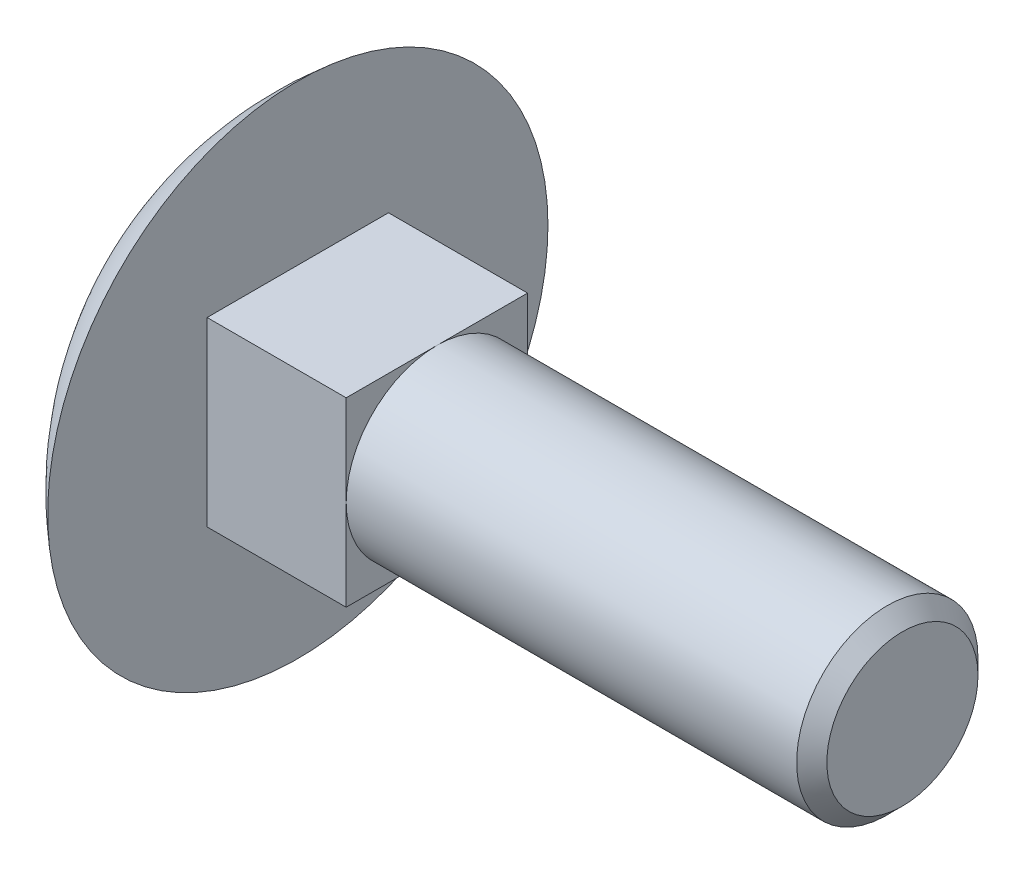
from build123d import *

# Parameters (mm, degrees)
SKIZZE2_W               = 6
SKIZZE2_H               = 6
LINEAR_AUSTRAGEN1_DEPTH = 4.6
SKIZZE3_R               = 3
LINEAR_AUSTRAGEN2_DEPTH = 15.4
FASE1_SIZE              = 0.5


with BuildPart() as part:
    # Skizze1 → Rotation1 (revolve)
    with BuildSketch(Plane(origin=(0, 0, 0), x_dir=(1, 0, 0), z_dir=(0, 1, 0))):
        with BuildLine():
            Line((0, 0), (0, 8.275))
            ThreePointArc((0, 8.275), (-2.861847997, 4.569738094), (-3.88, 0))
            Line((-3.88, 0), (0, 0))
        make_face()
    revolve(axis=Axis((0, 0, 0), (-1, 0, 0)))

    # Skizze2 → Linear austragen1 (add)
    with BuildSketch(Plane(origin=(0, 0, 0), x_dir=(0, 0, -1), z_dir=(1, 0, 0))):
        Rectangle(SKIZZE2_W, SKIZZE2_H)
    extrude(amount=LINEAR_AUSTRAGEN1_DEPTH)

    # Skizze3 → Linear austragen2 (add)
    with BuildSketch(Plane(origin=(4.6, 0, 0), x_dir=(0, 0, -1), z_dir=(1, 0, 0))):
        Circle(SKIZZE3_R)
    extrude(amount=LINEAR_AUSTRAGEN2_DEPTH)

    # Fase1
    fase1_edges = [part.edges().sort_by_distance(p)[0] for p in [
        (20, 0, 3),
    ]]
    chamfer(fase1_edges, length=FASE1_SIZE)


solid = part.part
